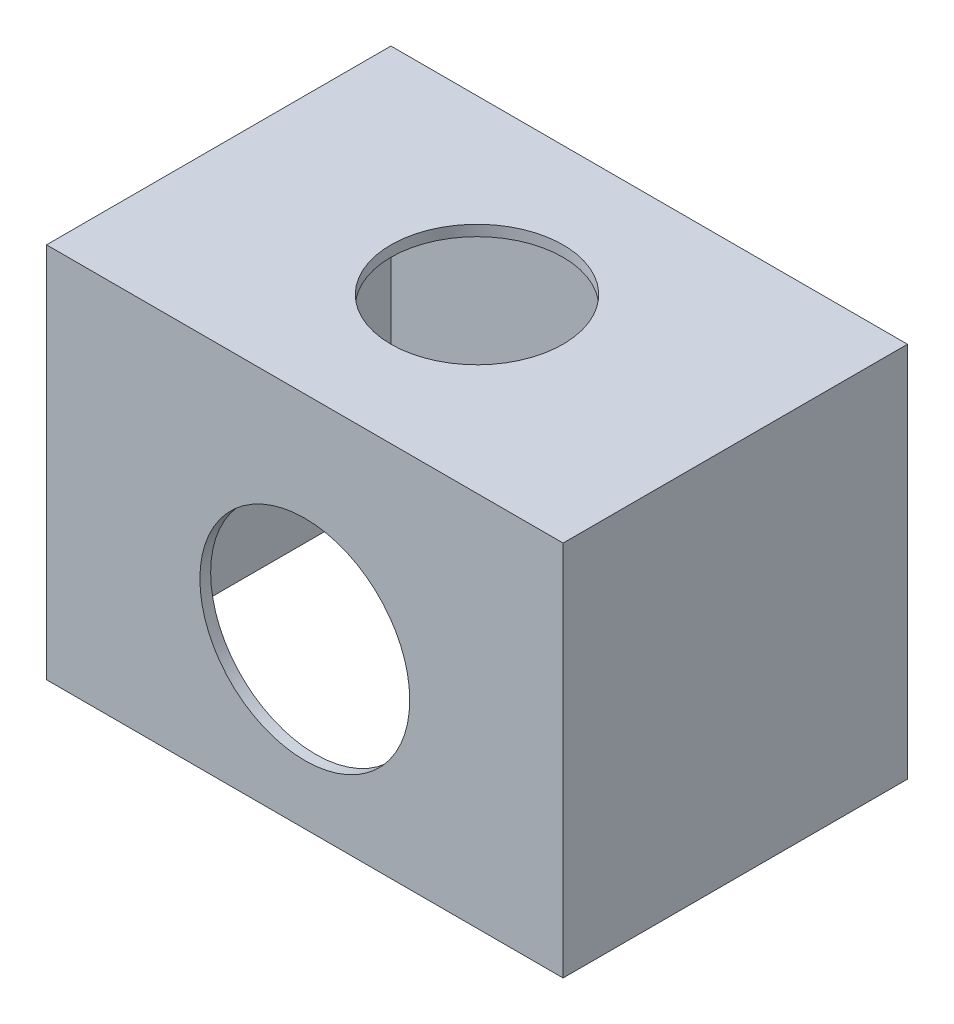
from build123d import *

# Parameters (mm, degrees)
CROQUIS1_W              = 96
CROQUIS1_H              = 64
SALIENTE_EXTRUIR1_DEPTH = 70
VACIADO1_T              = -2
CROQUIS2_R              = 16
CORTAR_EXTRUIR1_DEPTH   = 5
CROQUIS3_R              = 19.5
CORTAR_EXTRUIR2_DEPTH   = 5


with BuildPart() as part:
    # Croquis1 → Saliente-Extruir1 (new body)
    with BuildSketch(Plane(origin=(0, 0, 0), x_dir=(1, 0, 0), z_dir=(0, 1, 0))):
        Rectangle(CROQUIS1_W, CROQUIS1_H)
    extrude(amount=SALIENTE_EXTRUIR1_DEPTH)

    # Vaciado1
    vaciado1_openings = [part.faces().sort_by_distance(p)[0] for p in [
        (0, 0, 0),
    ]]
    offset(amount=VACIADO1_T, openings=vaciado1_openings, kind=Kind.INTERSECTION)

    # Croquis2 → Cortar-Extruir1 (cut)
    with BuildSketch(Plane(origin=(0, 70, 0), x_dir=(1, 0, 0), z_dir=(0, 1, 0))):
        Circle(CROQUIS2_R)
    extrude(amount=-CORTAR_EXTRUIR1_DEPTH, mode=Mode.SUBTRACT)

    # Croquis3 → Cortar-Extruir2 (cut)
    with BuildSketch(Plane.XY.offset(32)):
        with Locations((0, 30.5)):
            Circle(CROQUIS3_R)
    extrude(amount=-CORTAR_EXTRUIR2_DEPTH, mode=Mode.SUBTRACT)


solid = part.part
